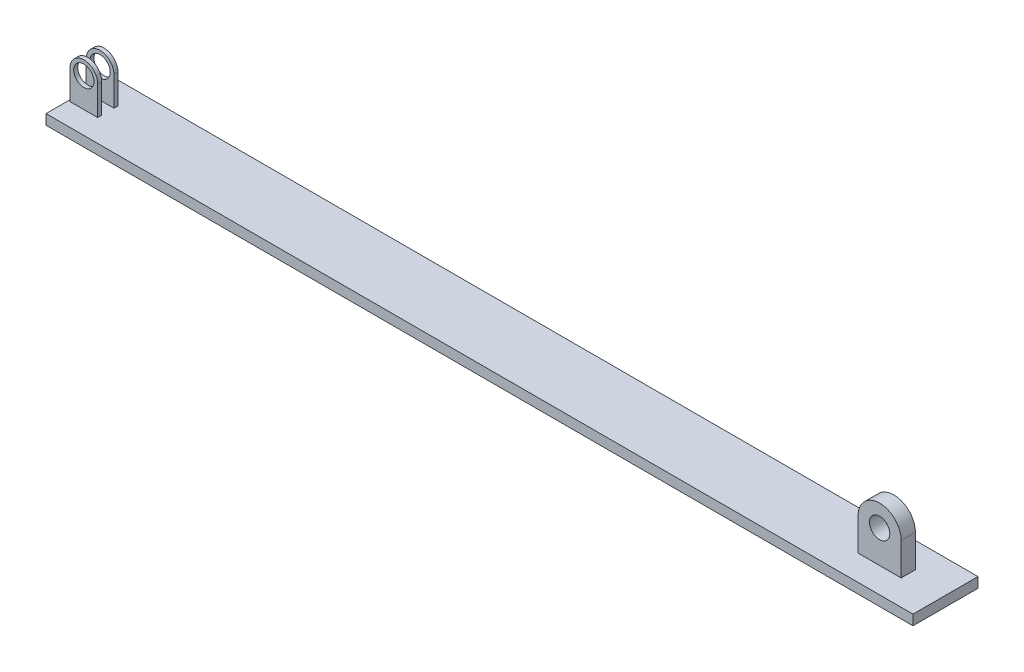
from build123d import *

# Parameters (mm, degrees)
SKETCH1_W          = 426.72
SKETCH1_H          = 5
EXTRUDE2_DEPTH     = 16
SKETCH2_R          = 5
EXTRUDE3_DEPTH     = 5
SKETCH3_W          = 6
SKETCH3_H          = 40.995425817
CUT_EXTRUDE1_DEPTH = 13.626819
SKETCH4_R          = 5
EXTRUDE4_DEPTH     = 3.5


with BuildPart() as part:
    # Sketch1 → Extrude2 (new body, symmetric)
    with BuildSketch(Plane(origin=(0, 0, 0), x_dir=(1, 0, 0), z_dir=(0, 0, -1))):
        with Locations((213.36, 0)):
            Rectangle(SKETCH1_W, SKETCH1_H)
    extrude(amount=EXTRUDE2_DEPTH, both=True)

    # Sketch2 → Extrude3 (add, symmetric)
    with BuildSketch(Plane.XY):
        with BuildLine():
            Line((0.803073324, 2.5), (0.803073324, 16.921503506))
            ThreePointArc((0.803073324, 16.921503506), (7.616482736, 23.734912918), (14.429892147, 16.921503506))
            Line((14.429892147, 16.921503506), (14.429892147, 2.5))
            Line((14.429892147, 2.5), (0.803073324, 2.5))
        make_face()
        with Locations((7.616482736, 16.921503506)):
            Circle(SKETCH2_R, mode=Mode.SUBTRACT)
    extrude(amount=EXTRUDE3_DEPTH, both=True)

    # Sketch3 → Cut-Extrude1 (cut)
    with BuildSketch(Plane.ZY.offset(-0.803073324)):
        with Locations((0, 22.997712909)):
            Rectangle(SKETCH3_W, SKETCH3_H)
    extrude(amount=-CUT_EXTRUDE1_DEPTH, mode=Mode.SUBTRACT)

    # Sketch4 → Extrude4 (add, symmetric)
    with BuildSketch(Plane.XY):
        with BuildLine():
            Line((408.398633308, 2.5), (408.398633308, 18.51574669))
            ThreePointArc((408.398633308, 18.51574669), (397.805657025, 29.108722972), (387.212680742, 18.51574669))
            Line((387.212680742, 18.51574669), (387.212680742, 2.5))
            Line((387.212680742, 2.5), (408.398633308, 2.5))
        make_face()
        with Locations((397.805657025, 18.51574669)):
            Circle(SKETCH4_R, mode=Mode.SUBTRACT)
    extrude(amount=EXTRUDE4_DEPTH, both=True)


solid = part.part
